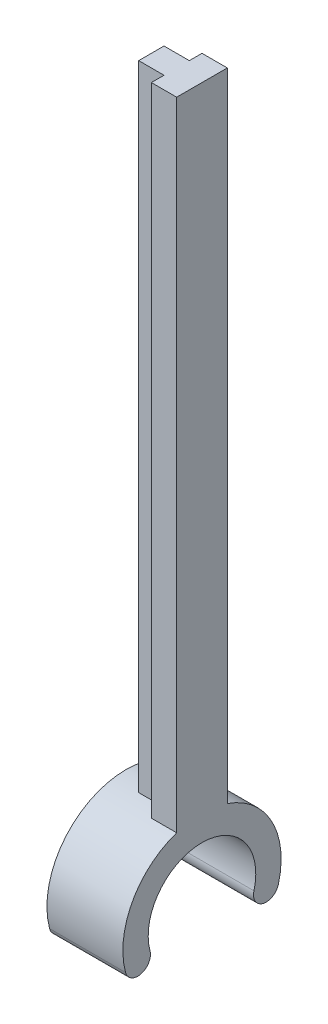
from build123d import *

# Parameters (mm, degrees)
BOSS_EXTRUDE1_DEPTH      = 2
BOSS_EXTRUDE1_DEPTH_BACK = 4
BOSS_EXTRUDE2_DEPTH      = 2
BOSS_EXTRUDE3_DEPTH      = 2


with BuildPart() as part:
    # Sketch1 → Boss-Extrude1 (new body, two sides)
    with BuildSketch(Plane(origin=(0, 0, 0), x_dir=(0, 0, -1), z_dir=(1, 0, 0))) as boss_extrude1_sk:
        with BuildLine():
            Line((-6.25, 0), (-4.25, 0))
            ThreePointArc((-4.25, 0), (0, 4.25), (4.25, 0))
            ThreePointArc((4.25, 0), (4.213640661, -0.554736317), (4.105184762, -1.099980942))
            Line((4.105184762, -1.099980942), (6.037036414, -1.617619032))
            ThreePointArc((6.037036414, -1.617619032), (6.196530384, -0.815788701), (6.25, 0))
            ThreePointArc((6.25, 0), (0, 6.25), (-6.25, 0))
        make_face()
        with BuildLine():
            Line((6.037036414, -1.617619032), (4.105184762, -1.099980942))
            ThreePointArc((4.105184762, -1.099980942), (4.812291543, -2.324725813), (6.037036414, -1.617619032))
        make_face()
        with BuildLine():
            ThreePointArc((-4.105184762, -1.099980942), (-4.213640661, -0.554736317), (-4.25, 0))
            Line((-4.25, 0), (-6.25, 0))
            ThreePointArc((-6.25, 0), (-6.196530384, -0.815788701), (-6.037036414, -1.617619032))
            Line((-6.037036414, -1.617619032), (-5.071110588, -1.358799987))
            Line((-5.071110588, -1.358799987), (-4.105184762, -1.099980942))
        make_face()
        with BuildLine():
            ThreePointArc((-6.037036414, -1.617619032), (-4.812291543, -2.324725813), (-4.105184762, -1.099980942))
            Line((-4.105184762, -1.099980942), (-5.071110588, -1.358799987))
            Line((-5.071110588, -1.358799987), (-6.037036414, -1.617619032))
        make_face()
    extrude(amount=BOSS_EXTRUDE1_DEPTH)
    extrude(boss_extrude1_sk.sketch, amount=-BOSS_EXTRUDE1_DEPTH_BACK)

    # Sketch2 → Boss-Extrude2 (add)
    with BuildSketch(Plane(origin=(0, 0, 0), x_dir=(0, 0, -1), z_dir=(1, 0, 0))):
        Polygon((-2, 4.25), (0, 4.25), (2, 4.25), (2, 56.25), (-2, 56.25), align=None)
    extrude(amount=BOSS_EXTRUDE2_DEPTH)

    # Sketch3 → Boss-Extrude3 (add)
    with BuildSketch(Plane(origin=(0, 0, 0), x_dir=(0, 0, -1), z_dir=(1, 0, 0))):
        Polygon((1, 56.25), (0, 56.25), (-1, 56.25), (-1, 4.25), (1, 4.25), align=None)
    extrude(amount=-BOSS_EXTRUDE3_DEPTH)


solid = part.part
